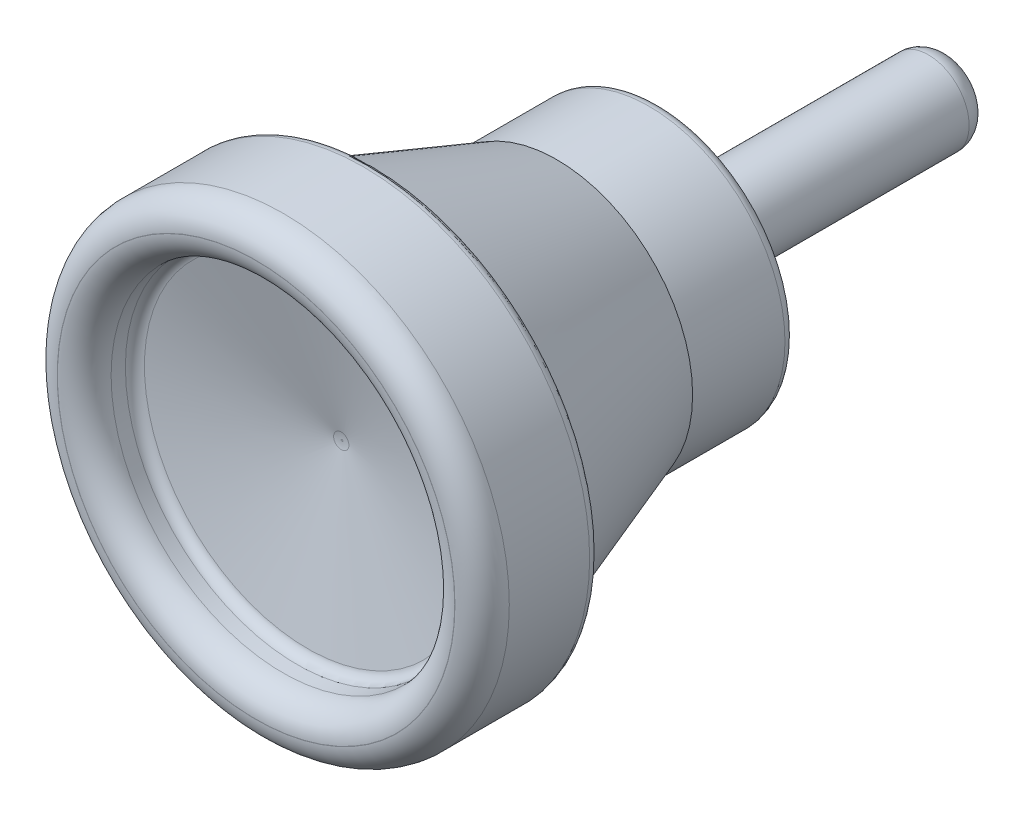
from build123d import *

# Parameters (mm, degrees)
SZKIC2_R                    = 1.9
DODANIE_WYCI_GNI_CIE1_DEPTH = 13.5
ZAOKR_GLENIE1_R             = 1


with BuildPart() as part:
    # Szkic1 → Obrót1 (revolve)
    with BuildSketch(Plane(origin=(0, 0, 0), x_dir=(1, 0, 0), z_dir=(0, 1, 0))):
        with BuildLine():
            Line((0, 4), (0, 18.8))
            Line((0, 18.8), (5.825, 18.8))
            ThreePointArc((5.825, 18.8), (6.178553391, 18.653553391), (6.325, 18.3))
            Line((6.325, 18.3), (6.325, 14))
            Line((6.325, 14), (9.076822804, 6.247973417))
            ThreePointArc((9.076822804, 6.247973417), (9.166319625, 6.092270066), (9.305060126, 5.978233721))
            Line((9.305060126, 5.978233721), (10.267955404, 5.44290566))
            ThreePointArc((10.267955404, 5.44290566), (10.455974304, 5.259399287), (10.525, 5.005901459))
            Line((10.525, 5.005901459), (10.525, 1.265))
            ThreePointArc((10.525, 1.265), (10.154490078, 0.370509922), (9.26, 0))
            Line((9.26, 0), (9.25, 0))
            ThreePointArc((9.25, 0), (8.366116524, 0.366116524), (8, 1.25))
            Line((8, 1.25), (8, 1.914093942))
            ThreePointArc((8, 1.914093942), (7.888187653, 2.229229382), (7.602758617, 2.40342069))
            Line((7.602758617, 2.40342069), (0.356322322, 3.966285408))
            ThreePointArc((0.356322322, 3.966285408), (0.199098874, 3.991547537), (0.040083327, 4))
            Line((0.040083327, 4), (0, 4))
        make_face()
    revolve(axis=Axis((0, 0, -4), (0, 0, -1)))

    # Szkic2 → Dodanie-wyciągnięcie1 (add)
    with BuildSketch(Plane(origin=(0, 0, -18.8), x_dir=(-1, 0, 0), z_dir=(0, 0, -1))):
        Circle(SZKIC2_R)
    extrude(amount=DODANIE_WYCI_GNI_CIE1_DEPTH)

    # Zaokrąglenie1
    zaokr_glenie1_edges = [part.edges().sort_by_distance(p)[0] for p in [
        (1.9, 0, -32.3),
    ]]
    fillet(zaokr_glenie1_edges, radius=ZAOKR_GLENIE1_R)


solid = part.part
